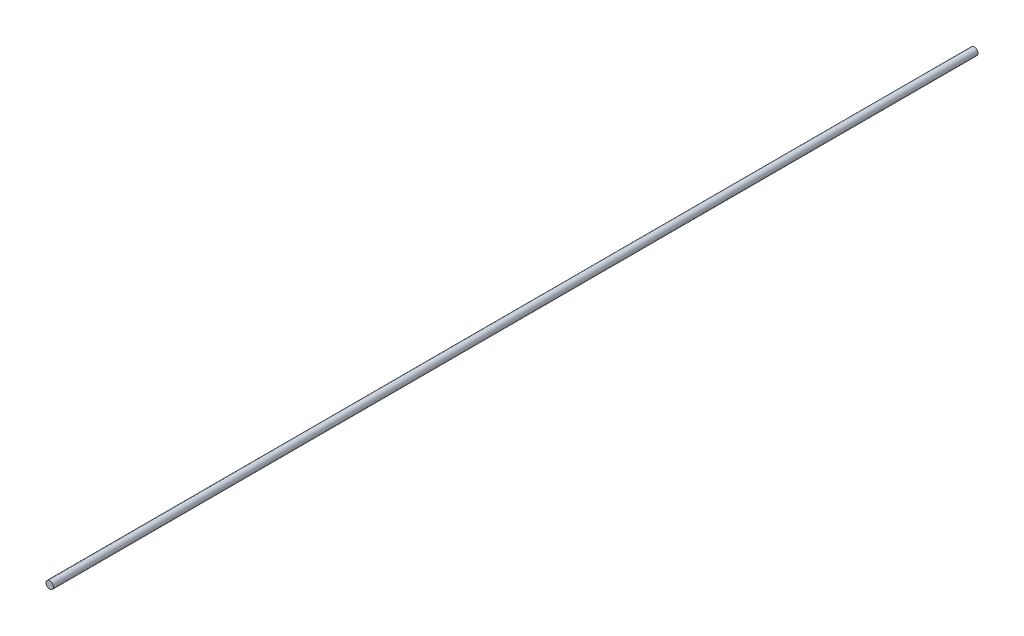
from build123d import *

# Parameters (mm, degrees)
SKETCH1_R           = 4
BOSS_EXTRUDE1_DEPTH = 500


with BuildPart() as part:
    # Sketch1 → Boss-Extrude1 (new body, symmetric)
    with BuildSketch(Plane.XY):
        Circle(SKETCH1_R)
    extrude(amount=BOSS_EXTRUDE1_DEPTH, both=True)


solid = part.part
